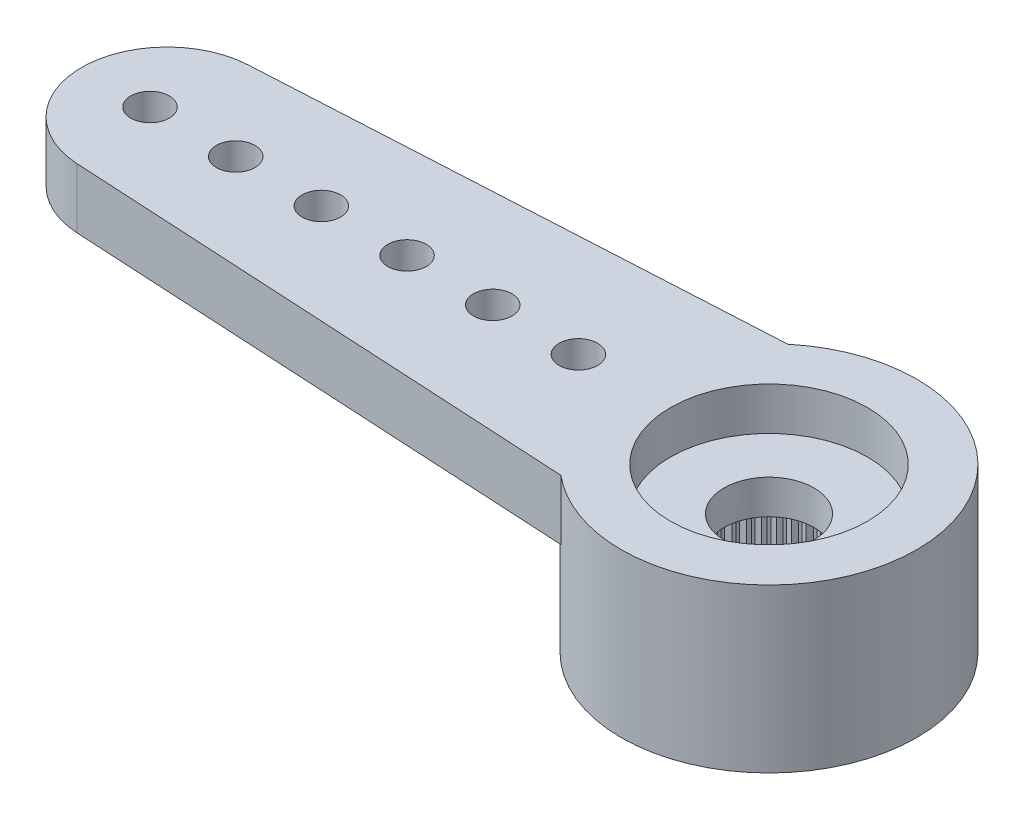
from build123d import *

# Parameters (mm, degrees)
RESSALTO_EXTRUS_O1_DEPTH = 1.4
ESBO_O2_R                = 3.45
RESSALTO_EXTRUS_O2_DEPTH = 2.4
FURO4_D                  = 0.9
PADR_O_LINEAR1_COUNT     = 6
PADR_O_LINEAR1_PITCH     = 2
FURO1_D                  = 4.95
FURO1_DEPTH              = 2
FURO2_D                  = 4.6
FURO2_DEPTH              = 1
FURO3_D                  = 2.1
RESSALTO_EXTRUS_O3_DEPTH = 2
PADR_OCIRCULAR1_COUNT    = 60


with BuildPart() as part:
    # Esboço1 → Ressalto-extrusão1 (new body)
    with BuildSketch(Plane(origin=(0, 0, 0), x_dir=(1, 0, 0), z_dir=(0, 1, 0))):
        with BuildLine():
            Line((-14.159121967, 1.99702088), (-2.209072203, 2.65))
            ThreePointArc((-2.209072203, 2.65), (3.45, 0), (-2.209072203, -2.65))
            Line((-2.209072203, -2.65), (-14.159121967, -1.99702088))
            ThreePointArc((-14.159121967, -1.99702088), (-16.05, 0), (-14.159121967, 1.99702088))
        make_face()
    extrude(amount=-RESSALTO_EXTRUS_O1_DEPTH)

    # Esboço2 → Ressalto-extrusão2 (add)
    with BuildSketch(Plane.XZ.offset(1.4)):
        Circle(ESBO_O2_R)
    extrude(amount=RESSALTO_EXTRUS_O2_DEPTH)

    # Furo4 (through all)
    with Locations(Plane(origin=(0, 0, 0), x_dir=(1, 0, 0), z_dir=(0, 1, 0))):
        with Locations((-14.45, 0)):
            furo4 = Hole(FURO4_D / 2)

    # Padrão linear1: Furo4 ×6
    with Locations(*[(i * PADR_O_LINEAR1_PITCH, 0, 0) for i in range(1, PADR_O_LINEAR1_COUNT)]):
        add(furo4, mode=Mode.SUBTRACT)

    # Furo1
    with Locations(Plane(origin=(0, -3.8, 0), x_dir=(-1, 0, 0), z_dir=(0, -1, 0))):
        with Locations((0, 0)):
            Hole(FURO1_D / 2, depth=FURO1_DEPTH)

    # Furo2
    with Locations(Plane(origin=(0, 0, 0), x_dir=(1, 0, 0), z_dir=(0, 1, 0))):
        with Locations((0, 0)):
            Hole(FURO2_D / 2, depth=FURO2_DEPTH)

    # Furo3 (through all)
    with Locations(Plane(origin=(0, 0, 0), x_dir=(1, 0, 0), z_dir=(0, 1, 0))):
        with Locations((0, 0)):
            Hole(FURO3_D / 2)

    # Esboço11 → Ressalto-extrusão3 (add)
    with BuildSketch(Plane.XZ.offset(3.8)):
        with BuildLine():
            Line((-0.098056786, 2.473056786), (0, 2.375))
            Line((0, 2.375), (0.098056786, 2.473056786))
            ThreePointArc((0.098056786, 2.473056786), (0, 2.475), (-0.098056786, 2.473056786))
        make_face()
    ressalto_extrus_o3 = extrude(amount=-RESSALTO_EXTRUS_O3_DEPTH)

    # PadrãoCircular1: Ressalto-extrusão3 ×60 about axis
    padr_ocircular1_axis = Axis((0, 0, 0), (0, 1, 0))
    for i in range(1, PADR_OCIRCULAR1_COUNT):
        add(ressalto_extrus_o3.rotate(padr_ocircular1_axis, i * 360 / PADR_OCIRCULAR1_COUNT))


solid = part.part
